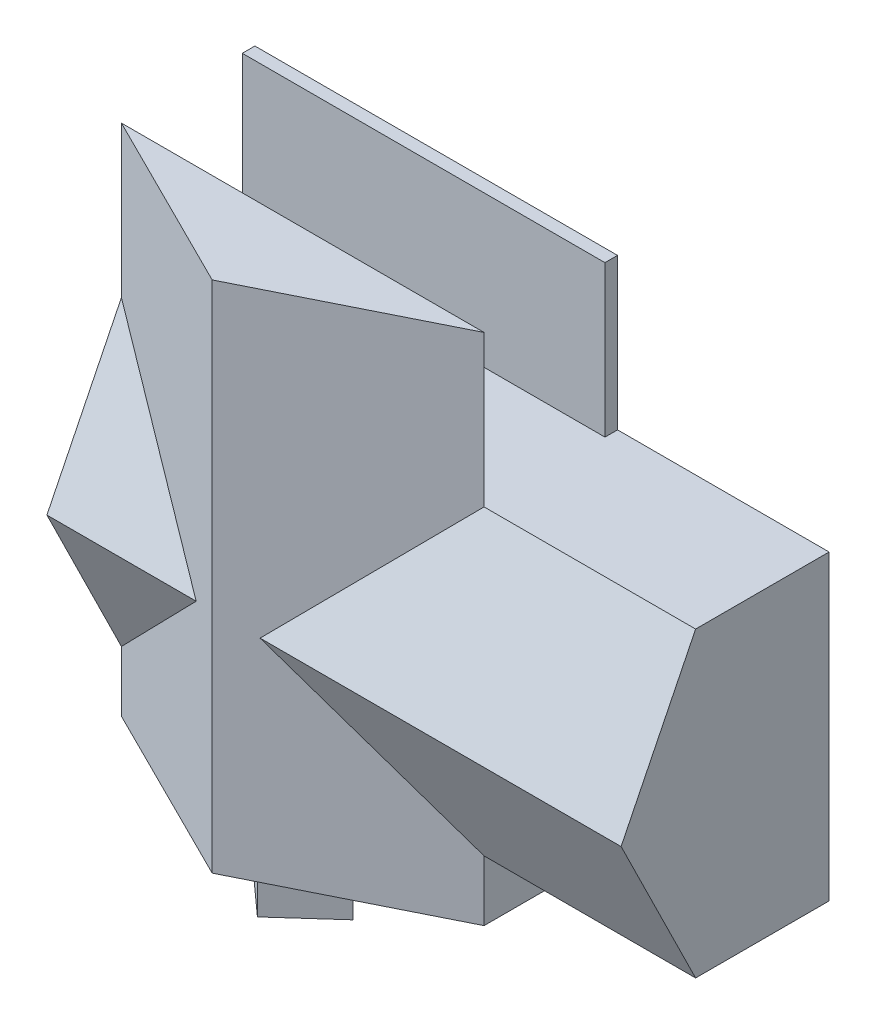
from build123d import *

# Parameters (mm, degrees)
SKETCH3_W           = 11582.4
SKETCH3_H           = 6096
SKETCH3_W_2         = 4341.154286856
SKETCH3_H_2         = 914.4
SKETCH3_W_3         = 1676.4
SKETCH3_H_3         = 2330.801356814
SKETCH3_W_4         = 2663.595025017
SKETCH3_H_4         = 2342.798643186
SKETCH3_W_5         = 1043.645713144
SKETCH3_W_6         = 4013.2
SKETCH3_W_7         = 3708.4
BOSS_EXTRUDE1_DEPTH = 2438.4
SKETCH4_W           = 11582.4
SKETCH4_H           = 6096
BOSS_EXTRUDE2_DEPTH = 254
SKETCH5_W           = 3178.404974983
SKETCH5_H           = 101.6
BOSS_EXTRUDE3_DEPTH = 1016
BOSS_EXTRUDE4_DEPTH = 11582.4
SKETCH8_W           = 7315.2
SKETCH8_H           = 3048
BOSS_EXTRUDE6_DEPTH = 254
BOSS_EXTRUDE7_DEPTH = 10363.2
SKETCH12_W          = 7315.2
SKETCH12_H          = 1219.2
BOSS_EXTRUDE8_DEPTH = 2692.4
BOSS_EXTRUDE9_DEPTH = 1219.2


with BuildPart() as part:
    # Sketch3 → Boss-Extrude1 (new body)
    with BuildSketch(Plane.XY):
        with Locations((5791.2, 3048)):
            Rectangle(SKETCH3_W, SKETCH3_H)
        Polygon((152.4, 152.4), (4550.004974983, 152.4), (4550.004974983, 2596.798643186), (5842, 2596.798643186), (5842, 3511.198643186), (5842, 5943.6), (152.4, 5943.6), align=None, mode=Mode.SUBTRACT)
        with Locations((8114.177143428, 3053.998643186)):
            Rectangle(SKETCH3_W_2, SKETCH3_H_2, mode=Mode.SUBTRACT)
        with Locations((6781.8, 4778.199321593)):
            Rectangle(SKETCH3_W_3, SKETCH3_H_3, mode=Mode.SUBTRACT)
        with Locations((5983.402487492, 1323.799321593)):
            Rectangle(SKETCH3_W_4, SKETCH3_H_4, mode=Mode.SUBTRACT)
        with Locations((10908.177143428, 3053.998643186)):
            Rectangle(SKETCH3_W_5, SKETCH3_H_2, mode=Mode.SUBTRACT)
        with Locations((9423.4, 1323.799321593)):
            Rectangle(SKETCH3_W_6, SKETCH3_H_4, mode=Mode.SUBTRACT)
        with Locations((9575.8, 4778.199321593)):
            Rectangle(SKETCH3_W_7, SKETCH3_H_3, mode=Mode.SUBTRACT)
    extrude(amount=BOSS_EXTRUDE1_DEPTH)

    # Sketch4 → Boss-Extrude2 (add)
    with BuildSketch(Plane(origin=(0, 0, 0), x_dir=(-1, 0, 0), z_dir=(0, 0, -1))):
        with Locations((-5791.2, 3048)):
            Rectangle(SKETCH4_W, SKETCH4_H)
    extrude(amount=BOSS_EXTRUDE2_DEPTH)

    # Sketch5 → Boss-Extrude3 (add)
    with BuildSketch(Plane.XY):
        with Locations((1741.602487492, 2545.998643186)):
            Rectangle(SKETCH5_W, SKETCH5_H)
    extrude(amount=BOSS_EXTRUDE3_DEPTH)

    # Sketch6 → Boss-Extrude4 (add)
    with BuildSketch(Plane.ZY):
        Polygon((2438.4, 6096), (2438.4, 0), (3941.507258543, 3048), align=None)
    extrude(amount=-BOSS_EXTRUDE4_DEPTH)

    # Sketch10 → Boss-Extrude7 (add)
    with BuildSketch(Plane(origin=(0, 9144, 0), x_dir=(1, 0, 0), z_dir=(0, 1, 0))):
        Polygon((7315.2, -2438.4), (0, -2438.4), (3655.110432816, -4263.253342026), align=None)
    extrude(amount=-BOSS_EXTRUDE7_DEPTH)

    # Sketch12 → Boss-Extrude8 (add)
    with BuildSketch(Plane(origin=(0, 0, -254), x_dir=(-1, 0, 0), z_dir=(0, 0, -1))):
        with Locations((-3657.6, -609.6)):
            Rectangle(SKETCH12_W, SKETCH12_H)
    extrude(amount=-BOSS_EXTRUDE8_DEPTH)

    # Sketch15 → Boss-Extrude9 (add)
    with BuildSketch(Plane.XZ.offset(1219.2)):
        Polygon((2641.6, 2438.4), (4673.6, 2438.4), (3657.6, 3352.8), align=None)
    extrude(amount=BOSS_EXTRUDE9_DEPTH)


with BuildPart() as body_2:
    # Sketch8 → Boss-Extrude6 (new body)
    with BuildSketch(Plane(origin=(0, 0, -254), x_dir=(-1, 0, 0), z_dir=(0, 0, -1))):
        with Locations((-3657.6, 7620)):
            Rectangle(SKETCH8_W, SKETCH8_H)
    extrude(amount=-BOSS_EXTRUDE6_DEPTH)


solid = Compound([part.part, body_2.part])
